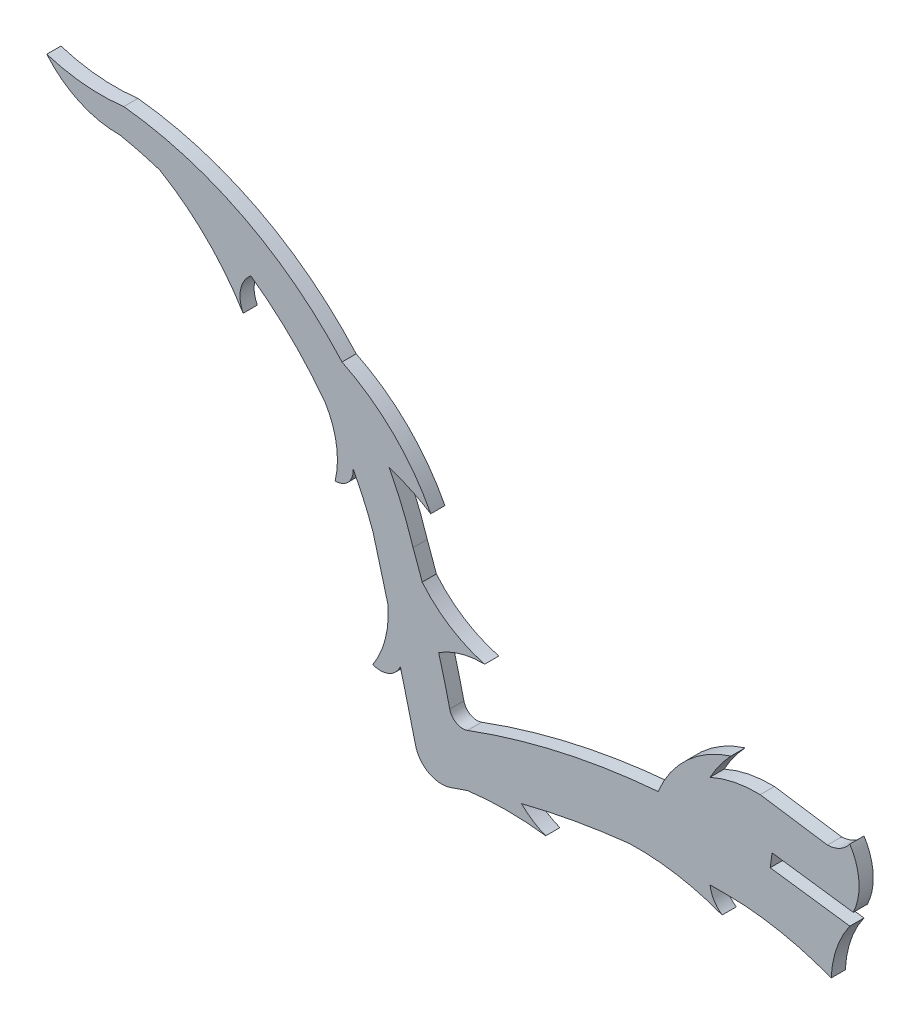
from build123d import *

# Parameters (mm, degrees)
BOSS_EXTRUDE1_DEPTH = 1.524


with BuildPart() as part:
    # Sketch1 → Boss-Extrude1 (new body)
    with BuildSketch(Plane.XY):
        with BuildLine():
            Line((-229.733299104, 584.719331839), (-222.502527935, 583.634973996))
            ThreePointArc((-222.502527935, 583.634973996), (-221.147267888, 584.004051618), (-220.092288362, 584.931395291))
            ThreePointArc((-220.092288362, 584.931395291), (-219.107825608, 581.890435474), (-219.721109978, 578.753480613))
            Line((-219.721109978, 578.753480613), (-228.459709631, 579.934984791))
            Line((-228.459709631, 579.934984791), (-228.661688518, 578.44207641))
            Line((-228.661688518, 578.44207641), (-220.092288362, 577.283710625))
            ThreePointArc((-220.092288362, 577.283710625), (-221.51932816, 574.510272261), (-222.100657588, 571.445886672))
            ThreePointArc((-222.100657588, 571.445886672), (-226.629664964, 572.833617667), (-231.313271906, 573.541806308))
            ThreePointArc((-231.313271906, 573.541806308), (-233.223508643, 573.597615767), (-235.134519327, 573.610155801))
            ThreePointArc((-235.134519327, 573.610155801), (-234.714498742, 572.38977797), (-233.834266637, 571.445886672))
            ThreePointArc((-233.834266637, 571.445886672), (-238.740309086, 572.778591559), (-243.812582366, 573.121226369))
            ThreePointArc((-243.812582366, 573.121226369), (-249.654593018, 572.281403909), (-255.423617198, 571.035309918))
            ThreePointArc((-255.423617198, 571.035309918), (-254.208732466, 570.049679285), (-252.813402451, 569.342242498))
            ThreePointArc((-252.813402451, 569.342242498), (-257.023373112, 569.616476447), (-261.233343772, 569.342242498))
            ThreePointArc((-261.233343772, 569.342242498), (-262.139462052, 569.036834334), (-263.042061741, 568.721179006))
            ThreePointArc((-263.042061741, 568.721179006), (-265.382908747, 568.898961953), (-266.820790496, 570.754674096))
            ThreePointArc((-266.820790496, 570.754674096), (-267.633321548, 574.021224174), (-268.462018281, 577.283710625))
            ThreePointArc((-268.462018281, 577.283710625), (-269.684214588, 576.035290864), (-271.430597221, 575.985658132))
            ThreePointArc((-271.430597221, 575.985658132), (-270.077505732, 579.055656064), (-269.795996664, 582.398782822))
            ThreePointArc((-269.795996664, 582.398782822), (-270.6063104, 585.428884975), (-271.430597221, 588.455215862))
            ThreePointArc((-271.430597221, 588.455215862), (-272.402462147, 590.846491133), (-273.540779849, 593.163159358))
            ThreePointArc((-273.540779849, 593.163159358), (-274.047233126, 591.694203826), (-275.473581255, 591.077878999))
            ThreePointArc((-275.473581255, 591.077878999), (-275.34428452, 594.597865441), (-276.57079113, 597.899789688))
            ThreePointArc((-276.57079113, 597.899789688), (-280.26245264, 602.086630283), (-284.548965797, 605.662074848))
            ThreePointArc((-284.548965797, 605.662074848), (-285.652879269, 603.854761803), (-285.375456051, 601.755228103))
            ThreePointArc((-285.375456051, 601.755228103), (-289.30709222, 606.735438718), (-294.333091655, 610.608369187))
            ThreePointArc((-294.333091655, 610.608369187), (-296.477583287, 611.240889296), (-298.65675661, 611.741018952))
            ThreePointArc((-298.65675661, 611.741018952), (-302.990086346, 612.65022374), (-306.51096198, 615.334964829))
            ThreePointArc((-306.51096198, 615.334964829), (-302.406354647, 614.521452362), (-298.222601436, 614.597695151))
            ThreePointArc((-298.222601436, 614.597695151), (-285.35767493, 610.750777653), (-274.736325292, 602.53542373))
            ThreePointArc((-274.736325292, 602.53542373), (-269.209056442, 598.616541826), (-265.187992407, 593.163159358))
            ThreePointArc((-265.187992407, 593.163159358), (-267.353928299, 594.342358031), (-269.657730455, 595.222291793))
            ThreePointArc((-269.657730455, 595.222291793), (-268.234509905, 592.198490903), (-267.092140084, 589.057803121))
            ThreePointArc((-267.092140084, 589.057803121), (-266.592090958, 587.698505955), (-266.111218097, 586.33230714))
            ThreePointArc((-266.111218097, 586.33230714), (-263.083103018, 583.668794976), (-259.392672976, 582.04260185))
            ThreePointArc((-259.392672976, 582.04260185), (-261.970528382, 581.721095666), (-264.339245348, 580.654378901))
            ThreePointArc((-264.339245348, 580.654378901), (-263.715375229, 578.327001479), (-263.146155659, 575.985658132))
            ThreePointArc((-263.146155659, 575.985658132), (-262.422892661, 575.037653784), (-261.233343772, 574.955221701))
            ThreePointArc((-261.233343772, 574.955221701), (-251.134066148, 577.939069272), (-240.721980879, 579.516166347))
            ThreePointArc((-240.721980879, 579.516166347), (-237.604479811, 584.0033655), (-232.878306602, 586.745090494))
            ThreePointArc((-232.878306602, 586.745090494), (-234.104874481, 585.261460478), (-235.134519327, 583.634973996))
            ThreePointArc((-235.134519327, 583.634973996), (-232.495519695, 584.484036639), (-229.733299104, 584.719331839))
        make_face()
    extrude(amount=BOSS_EXTRUDE1_DEPTH)


solid = part.part
